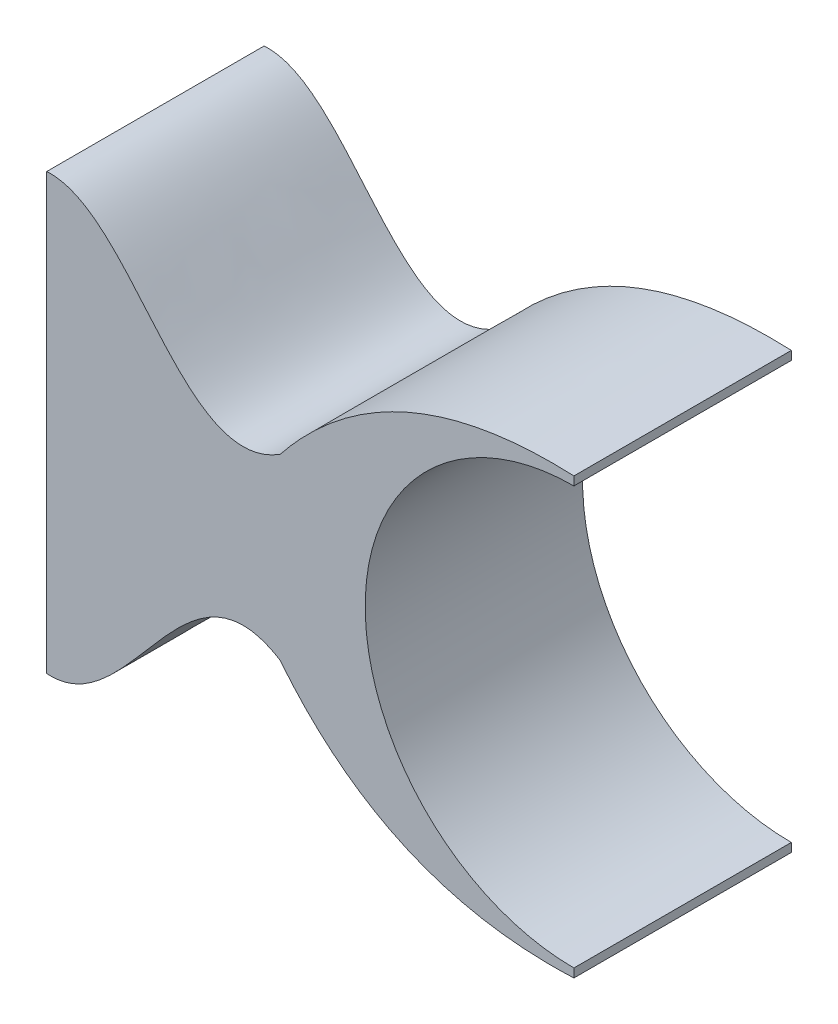
from build123d import *

# Parameters (mm, degrees)
BOSS_EXTRUDE1_DEPTH = 2.5


with BuildPart() as part:
    # Sketch1 → Boss-Extrude1 (new body)
    with BuildSketch(Plane.XY):
        with BuildLine():
            Line((-6.062552239, 2.5), (-6.062552239, -2.5))
            add(Edge.make_bspline(
                [(-3.378314474, -1.025559537), (-4.49216768, -0.325238314), (-5.082460235, -2.568455815), (-6.062552239, -2.5)],
                knots=[0, 0, 0, 0, 1, 1, 1, 1], degree=3))
            add(Edge.make_bspline(
                [(0, -2.5), (-2.128381344, -2.596064875), (-3.378314474, -1.025559537)],
                knots=[0, 0, 0, 1, 1, 1], degree=2))
            Line((0, -2.5), (0, -2.4))
            ThreePointArc((0, -2.4), (-2.4, 0), (0, 2.4))
            Line((0, 2.4), (0, 2.5))
            add(Edge.make_bspline(
                [(0, 2.5), (-2.128381344, 2.596064875), (-3.378314474, 1.025559537)],
                knots=[0, 0, 0, 1, 1, 1], degree=2))
            add(Edge.make_bspline(
                [(-3.378314474, 1.025559537), (-4.49216768, 0.325238314), (-5.082460235, 2.568455815), (-6.062552239, 2.5)],
                knots=[0, 0, 0, 0, 1, 1, 1, 1], degree=3))
        make_face()
    extrude(amount=BOSS_EXTRUDE1_DEPTH)


solid = part.part
